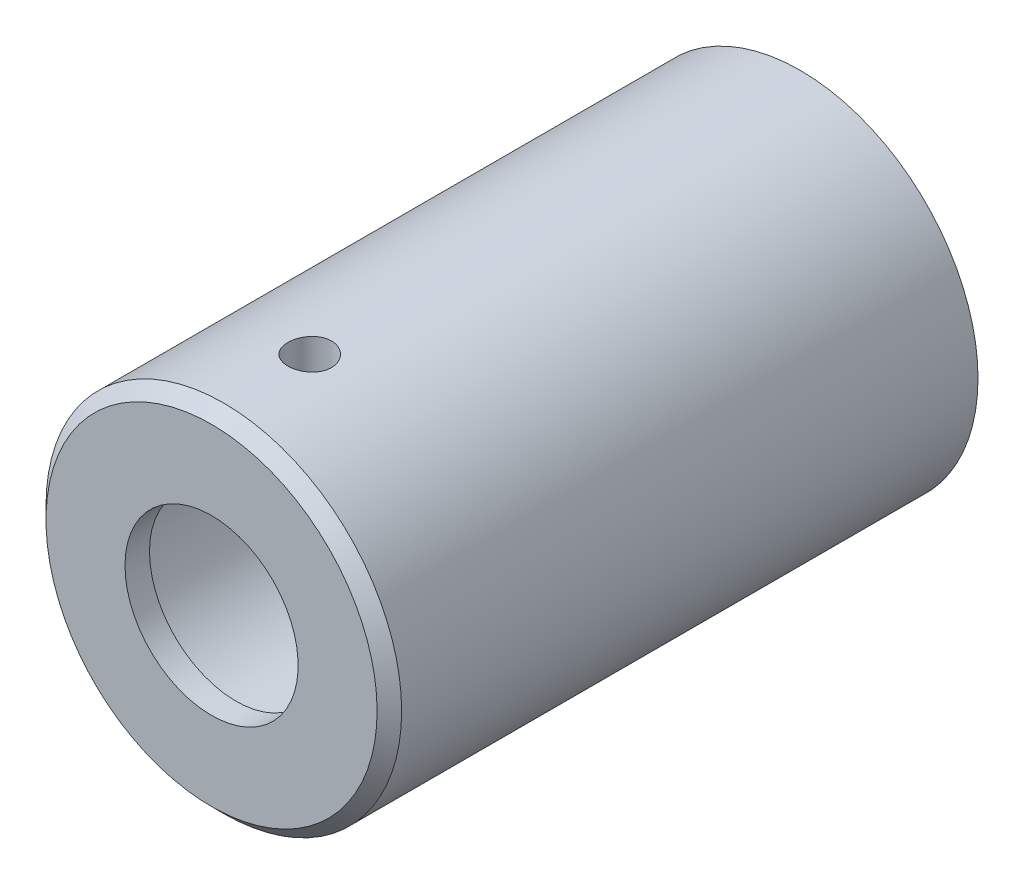
from build123d import *

# Parameters (mm, degrees)
F_2_56_TAPPED_HOLE2_REACH  = 16.5
F_2_56_TAPPED_HOLE2_BORE_R = 0.889
CHAMFER1_SIZE              = 0.5


with BuildPart() as part:
    # Sketch1 → Revolve1 (revolve)
    with BuildSketch(Plane(origin=(0, 0, 0), x_dir=(0, 0, -1), z_dir=(1, 0, 0)), mode=Mode.PRIVATE) as revolve1_sk:
        Polygon((0, 7.25), (0, 3.53), (1, 3.53), (1, 4.53), (24, 4.53), (24, 7.25), align=None)
    revolve(revolve1_sk.sketch.rotate(Axis((0, 0, 0), (0, 0, 1)), 90), axis=Axis((0, 0, 0), (0, 0, 1)))  # turned: the seam where the file's is

    # #2-56 Tapped Hole2 bore (on position points) → #2-56 Tapped Hole2 (cut, up to next)
    with BuildSketch(Plane(origin=(0, 7.25, -4), x_dir=(1, 0, 0), z_dir=(0, 1, 0)), mode=Mode.PRIVATE) as f_2_56_tapped_hole2_sk1:
        Circle(F_2_56_TAPPED_HOLE2_BORE_R)
    f_2_56_tapped_hole2_tool1 = extrude(f_2_56_tapped_hole2_sk1.sketch, amount=-F_2_56_TAPPED_HOLE2_REACH, mode=Mode.PRIVATE) & part.part
    add(f_2_56_tapped_hole2_tool1.solids().sort_by_distance((0, 7.25, -4))[0], mode=Mode.SUBTRACT)

    # Chamfer1
    chamfer1_edges = [part.edges().sort_by_distance(p)[0] for p in [
        (7.25, 0, 0),
    ]]
    chamfer(chamfer1_edges, length=CHAMFER1_SIZE)


solid = part.part
